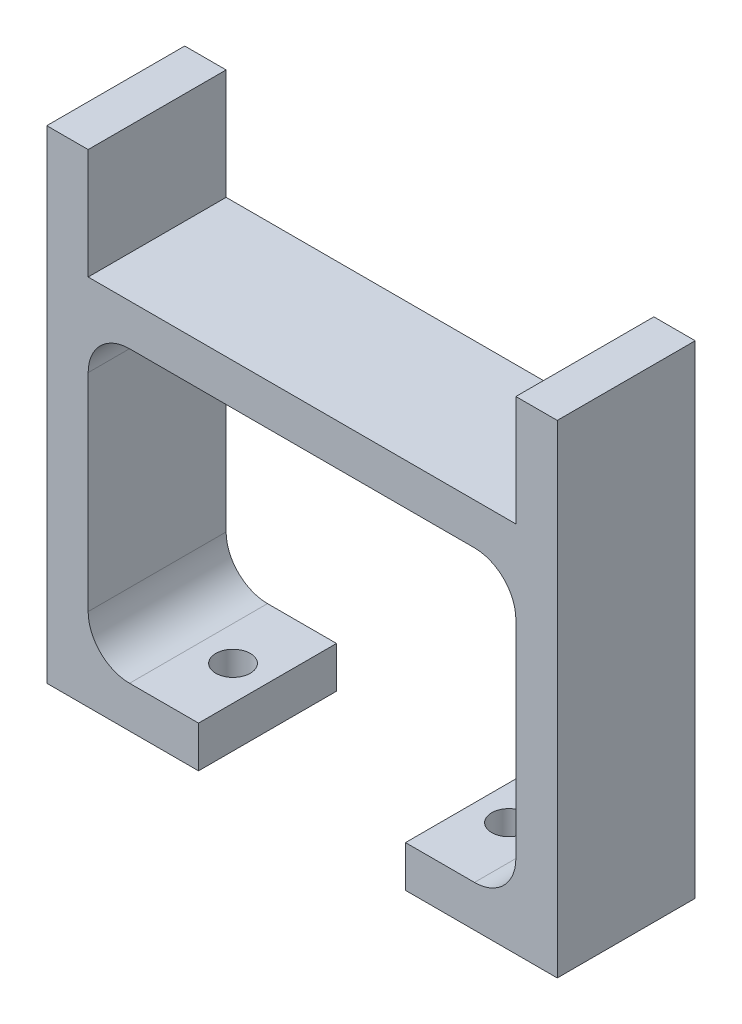
from build123d import *

# Parameters (mm, degrees)
BOSS_EXTRUDE1_DEPTH = 10
SKETCH2_R           = 1.25
CUT_EXTRUDE1_DEPTH  = 4


with BuildPart() as part:
    # Sketch1 → Boss-Extrude1 (new body)
    with BuildSketch(Plane.XY):
        with BuildLine():
            Line((-15.5, 27), (15.5, 27))
            Line((15.5, 27), (15.5, 35))
            Line((15.5, 35), (18.5, 35))
            Line((18.5, 35), (18.5, 0))
            Line((18.5, 0), (7.5, 0))
            Line((7.5, 0), (7.5, 3))
            Line((7.5, 3), (12.5, 3))
            ThreePointArc((12.5, 3), (14.621320344, 3.878679656), (15.5, 6))
            Line((15.5, 6), (15.5, 21))
            ThreePointArc((15.5, 21), (14.621320344, 23.121320344), (12.5, 24))
            Line((12.5, 24), (-12.5, 24))
            ThreePointArc((-12.5, 24), (-14.621320344, 23.121320344), (-15.5, 21))
            Line((-15.5, 21), (-15.5, 6))
            ThreePointArc((-15.5, 6), (-14.621320344, 3.878679656), (-12.5, 3))
            Line((-12.5, 3), (-7.5, 3))
            Line((-7.5, 3), (-7.5, 0))
            Line((-7.5, 0), (-18.5, 0))
            Line((-18.5, 0), (-18.5, 35))
            Line((-18.5, 35), (-15.5, 35))
            Line((-15.5, 35), (-15.5, 27))
        make_face()
    extrude(amount=BOSS_EXTRUDE1_DEPTH)

    # Sketch2 → Cut-Extrude1 (cut, through all)
    with BuildSketch(Plane(origin=(0, 3, 0), x_dir=(1, 0, 0), z_dir=(0, 1, 0))):
        with Locations((-10, -5)):
            Circle(SKETCH2_R)
        with Locations((10, -5)):
            Circle(SKETCH2_R)
    extrude(amount=-CUT_EXTRUDE1_DEPTH, mode=Mode.SUBTRACT)


solid = part.part
